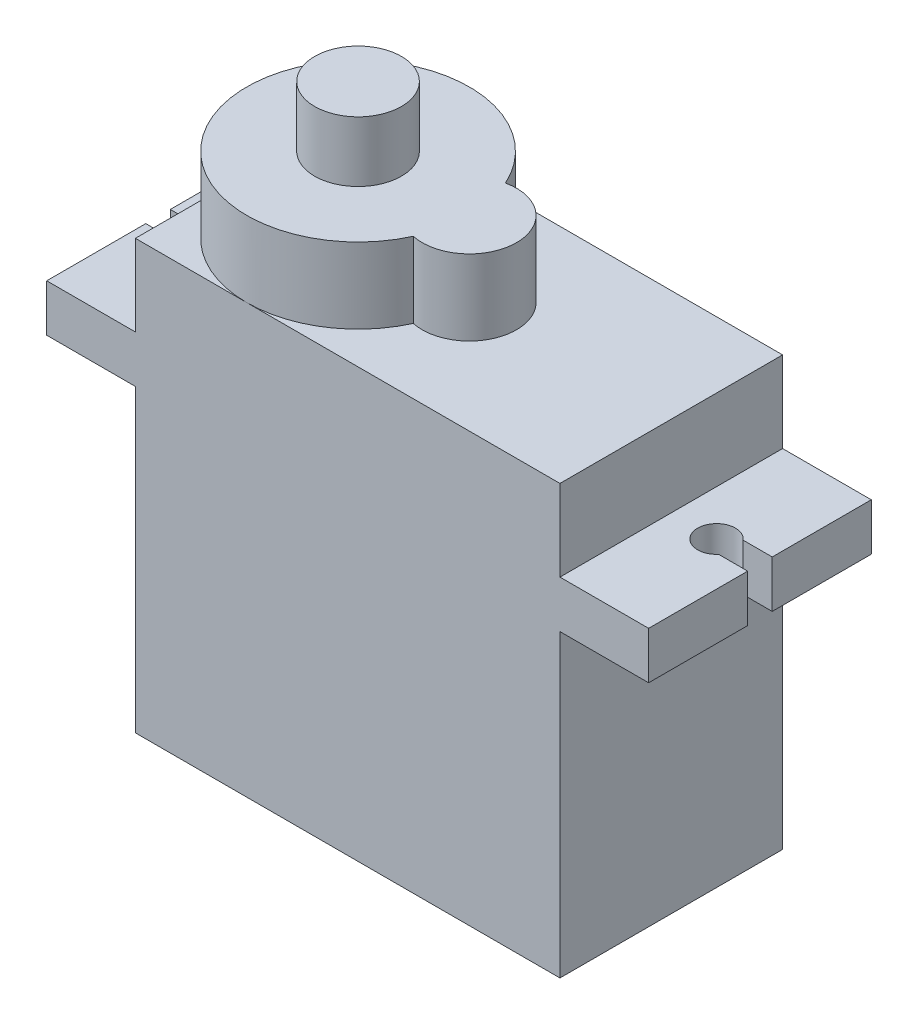
from build123d import *

# Parameters (mm, degrees)
BOSS_EXTRUDE1_DEPTH = 11.8
BOSS_EXTRUDE2_DEPTH = 4
SKETCH4_R           = 2.3
BOSS_EXTRUDE3_DEPTH = 3.2
CUT_EXTRUDE1_DEPTH  = 3.2
CUT_EXTRUDE2_DEPTH  = 3.2


with BuildPart() as part:
    # Sketch2 → Boss-Extrude1 (new body)
    with BuildSketch(Plane.XY):
        Polygon((0, 0), (22.5, 0), (22.5, 15.9), (27.2, 15.9), (27.2, 18.4), (22.5, 18.4), (22.5, 22.7), (0, 22.7), (0, 18.4), (-4.7, 18.4), (-4.7, 15.9), (0, 15.9), align=None)
    extrude(amount=BOSS_EXTRUDE1_DEPTH)

    # Sketch3 → Boss-Extrude2 (add)
    with BuildSketch(Plane(origin=(0, 22.7, 0), x_dir=(1, 0, 0), z_dir=(0, 1, 0))):
        with BuildLine():
            ThreePointArc((11.270338983, -3.456752324), (0, -5.9), (11.270338983, -8.343247676))
            ThreePointArc((11.270338983, -8.343247676), (14.3, -5.9), (11.270338983, -3.456752324))
        make_face()
    extrude(amount=BOSS_EXTRUDE2_DEPTH)

    # Sketch4 → Boss-Extrude3 (add)
    with BuildSketch(Plane(origin=(0, 26.7, 0), x_dir=(1, 0, 0), z_dir=(0, 1, 0))):
        with Locations((5.9, -5.9)):
            Circle(SKETCH4_R)
    extrude(amount=BOSS_EXTRUDE3_DEPTH)

    # Sketch5 → Cut-Extrude1 (cut)
    with BuildSketch(Plane(origin=(0, 18.4, 0), x_dir=(1, 0, 0), z_dir=(0, 1, 0))):
        with BuildLine():
            Line((27.2, -5.9), (27.2, -5.25))
            Line((27.2, -5.25), (25.659934208, -5.25))
            ThreePointArc((25.659934208, -5.25), (23.9, -5.9), (25.659934208, -6.55))
            Line((25.659934208, -6.55), (27.2, -6.55))
            Line((27.2, -6.55), (27.2, -5.9))
        make_face()
    extrude(amount=-CUT_EXTRUDE1_DEPTH, mode=Mode.SUBTRACT)

    # Sketch6 → Cut-Extrude2 (cut)
    with BuildSketch(Plane(origin=(0, 18.4, 0), x_dir=(1, 0, 0), z_dir=(0, 1, 0))):
        with BuildLine():
            Line((-4.7, -5.9), (-4.7, -5.25))
            Line((-4.7, -5.25), (-3.159934208, -5.25))
            ThreePointArc((-3.159934208, -5.25), (-1.4, -5.9), (-3.159934208, -6.55))
            Line((-3.159934208, -6.55), (-4.7, -6.55))
            Line((-4.7, -6.55), (-4.7, -5.9))
        make_face()
    extrude(amount=-CUT_EXTRUDE2_DEPTH, mode=Mode.SUBTRACT)


solid = part.part
